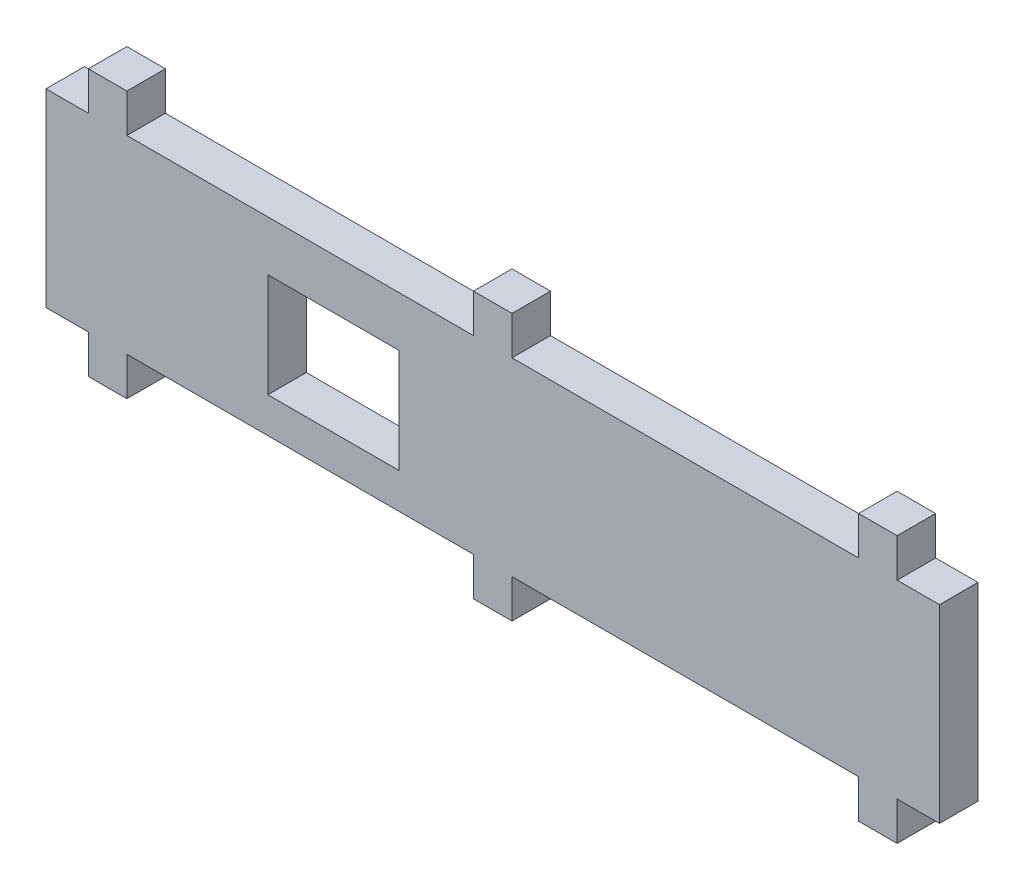
from build123d import *

# Parameters (mm, degrees)
SKETCH1_W           = 116
SKETCH1_H           = 12.3
BOSS_EXTRUDE1_DEPTH = 5
SKETCH2_W           = 5
SKETCH2_H           = 5
BOSS_EXTRUDE2_DEPTH = 5
SKETCH3_W           = 17
SKETCH3_H           = 13.5
CUT_EXTRUDE1_DEPTH  = 6


with BuildPart() as part:
    # Sketch1 → Boss-Extrude1 (new body)
    with BuildSketch(Plane.XY):
        Rectangle(SKETCH1_W, SKETCH1_H)
    extrude(amount=BOSS_EXTRUDE1_DEPTH)

    # Sketch2 → Boss-Extrude2 (add)
    with BuildSketch(Plane.XZ.offset(6.15)):
        with Locations((-50, 2.5)):
            Rectangle(SKETCH2_W, SKETCH2_H)
        with Locations((0, 2.5)):
            Rectangle(SKETCH2_W, SKETCH2_H)
        with Locations((50, 2.5)):
            Rectangle(SKETCH2_W, SKETCH2_H)
    extrude(amount=BOSS_EXTRUDE2_DEPTH)

    # Mirror1: part across plane


with BuildPart() as part_1:
    add(part.part)
    add(part.part.mirror(Plane(origin=(-58, 6.15, 5), x_dir=(0, 0, 1), z_dir=(0, -1, 0))))

    # Sketch3 → Cut-Extrude1 (cut, through all)
    with BuildSketch(Plane.XY.offset(5)):
        with Locations((-20.7, 5.2)):
            Rectangle(SKETCH3_W, SKETCH3_H)
    extrude(amount=-CUT_EXTRUDE1_DEPTH, mode=Mode.SUBTRACT)


solid = part_1.part
